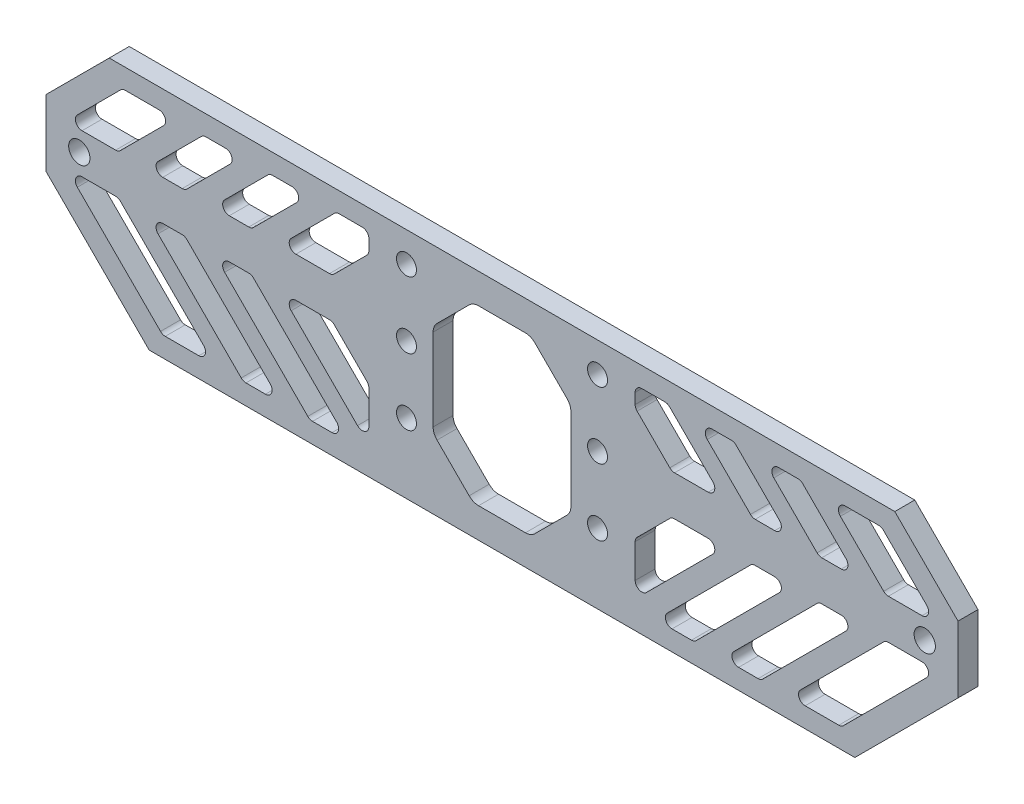
from build123d import *

# Parameters (mm, degrees)
SKETCH_1_W             = 32.7
SKETCH_1_H             = 29
SKETCH_1_R             = 1.5
EXTRUDE_1_DEPTH        = 3
CHAMFER_1_SIZE         = 3
EXTRUDE_2_DEPTH        = 3
CHAMFER_2_SIZE         = 9.5
EXTRUDE_3_DEPTH        = 3
SKETCH_6_R             = 1.6
CUT_EXTRUDE_2_DEPTH    = 4
CUT_EXTRUDE_4_DEPTH    = 10
FILLET_2_R             = 1
FILLET_2_OF_MIRROR_1_R = 1
SKETCH_8_W             = 20.7
SKETCH_8_H             = 26
CUT_EXTRUDE_5_DEPTH    = 10
CHAMFER_3_SIZE         = 6
FILLET_3_R             = 2


with BuildPart() as part:
    # 草图1 → 凸台-拉伸1 (new body)
    with BuildSketch(Plane.XY):
        Rectangle(SKETCH_1_W, SKETCH_1_H)
        with Locations((-14.35, -10)):
            Circle(SKETCH_1_R, mode=Mode.SUBTRACT)
        with Locations((-14.35, 10)):
            Circle(SKETCH_1_R, mode=Mode.SUBTRACT)
        with Locations((14.35, 10)):
            Circle(SKETCH_1_R, mode=Mode.SUBTRACT)
        with Locations((14.35, -10)):
            Circle(SKETCH_1_R, mode=Mode.SUBTRACT)
        with Locations((-14.35, 0)):
            Circle(SKETCH_1_R, mode=Mode.SUBTRACT)
        with Locations((14.35, 0)):
            Circle(SKETCH_1_R, mode=Mode.SUBTRACT)
    extrude(amount=EXTRUDE_1_DEPTH)

    # 倒角1
    chamfer_1_edges = [part.edges().sort_by_distance(p)[0] for p in [
        (16.35, -14.5, 1.5),
        (-16.35, -14.5, 1.5),
        (-16.35, 14.5, 1.5),
        (16.35, 14.5, 1.5),
    ]]
    chamfer(chamfer_1_edges, length=CHAMFER_1_SIZE)

    # 草图3 → 凸台-拉伸2 (add)
    with BuildSketch(Plane.XY.offset(3)):
        Polygon((-13.35, 14.5), (-68.5, 14.5), (-68.5, -14.5), (-13.35, -14.5), (-16.35, -11.5), (-16.35, 11.5), align=None)
        Polygon((68.5, 14.5), (13.35, 14.5), (16.35, 11.5), (16.35, -11.5), (13.35, -14.5), (68.5, -14.5), align=None)
    extrude(amount=-EXTRUDE_2_DEPTH)

    # 倒角2
    chamfer_2_edges = [part.edges().sort_by_distance(p)[0] for p in [
        (-68.5, -14.5, 1.5),
        (-68.5, 14.5, 1.5),
        (68.5, -14.5, 1.5),
        (68.5, 14.5, 1.5),
    ]]
    chamfer(chamfer_2_edges, length=CHAMFER_2_SIZE)

    # 草图4 → 凸台-拉伸3 (add)
    with BuildSketch(Plane(origin=(0, 0, 0), x_dir=(-1, 0, 0), z_dir=(0, 0, -1))):
        Polygon((-59, -14.5), (-53, -20.5), (53, -20.5), (59, -14.5), align=None)
    extrude(amount=-EXTRUDE_3_DEPTH)

    # 草图6 → 切除-拉伸2 (cut, through all)
    with BuildSketch(Plane(origin=(0, 0, 0), x_dir=(-1, 0, 0), z_dir=(0, 0, -1))):
        with Locations((-63.5, 0)):
            Circle(SKETCH_6_R)
    cut_extrude_2 = extrude(amount=-CUT_EXTRUDE_2_DEPTH, mode=Mode.SUBTRACT)

    # 草图7 → 切除-拉伸4 (cut)
    with BuildSketch(Plane(origin=(0, 0, 0), x_dir=(-1, 0, 0), z_dir=(0, 0, -1))):
        Polygon((-57, 11.5), (-65.5, 3), (-57.621320344, 3), (-49.121320344, 11.5), align=None)
        Polygon((-57.621320344, -3), (-65.5, -3), (-51, -17.5), (-43.121320344, -17.5), align=None)
        Polygon((-47.621320344, -3), (-53.378679656, -3), (-38.878679656, -17.5), (-33.121320344, -17.5), align=None)
        Polygon((-44.878679656, 11.5), (-53.378679656, 3), (-47.621320344, 3), (-39.121320344, 11.5), align=None)
        Polygon((-34.878679656, 11.5), (-43.378679656, 3), (-37.621320344, 3), (-29.121320344, 11.5), align=None)
        Polygon((-23.121320344, -17.5), (-37.621320344, -3), (-43.378679656, -3), (-28.878679656, -17.5), align=None)
        Polygon((-20, -8.5), (-25.5, -3), (-33.378679656, -3), (-20, -16.378679656), align=None)
        Polygon((-33.378679656, 3), (-25.5, 3), (-20, 8.5), (-20, 11.5), (-23, 11.5), (-24.878679656, 11.5), align=None)
    cut_extrude_4 = extrude(amount=-CUT_EXTRUDE_4_DEPTH, mode=Mode.SUBTRACT)

    # 圆角2
    fillet_2_edges = [part.edges().sort_by_distance(p)[0] for p in [
        (53.378679656, -3, 1.5),
        (47.621320344, -3, 1.5),
        (33.121320344, -17.5, 1.5),
        (38.878679656, -17.5, 1.5),
        (57.621320344, -3, 1.5),
        (43.121320344, -17.5, 1.5),
        (51, -17.5, 1.5),
        (65.5, -3, 1.5),
        (37.621320344, 3, 1.5),
        (43.378679656, 3, 1.5),
        (34.878679656, 11.5, 1.5),
        (29.121320344, 11.5, 1.5),
        (47.621320344, 3, 1.5),
        (53.378679656, 3, 1.5),
        (44.878679656, 11.5, 1.5),
        (39.121320344, 11.5, 1.5),
        (33.378679656, -3, 1.5),
        (25.5, -3, 1.5),
        (20, -8.5, 1.5),
        (20, -16.378679656, 1.5),
        (43.378679656, -3, 1.5),
        (37.621320344, -3, 1.5),
        (23.121320344, -17.5, 1.5),
        (28.878679656, -17.5, 1.5),
        (33.378679656, 3, 1.5),
        (24.878679656, 11.5, 1.5),
        (20, 11.5, 1.5),
        (20, 8.5, 1.5),
        (25.5, 3, 1.5),
        (57.621320344, 3, 1.5),
        (65.5, 3, 1.5),
        (57, 11.5, 1.5),
        (49.121320344, 11.5, 1.5),
    ]]
    fillet(fillet_2_edges, radius=FILLET_2_R)

    # 镜向1: 切除-拉伸2, 切除-拉伸4 across plane
    add(cut_extrude_2.mirror(Plane(origin=(0, 0, 0), x_dir=(0, 0, 1), z_dir=(1, 0, 0))), mode=Mode.SUBTRACT)
    add(cut_extrude_4.mirror(Plane(origin=(0, 0, 0), x_dir=(0, 0, 1), z_dir=(1, 0, 0))), mode=Mode.SUBTRACT)

    # 圆角2 of 镜向1
    fillet_2_of_mirror_1_edges = [part.edges().sort_by_distance(p)[0] for p in [
        (-53.378679656, -3, 1.5),
        (-47.621320344, -3, 1.5),
        (-33.121320344, -17.5, 1.5),
        (-38.878679656, -17.5, 1.5),
        (-57.621320344, -3, 1.5),
        (-43.121320344, -17.5, 1.5),
        (-51, -17.5, 1.5),
        (-65.5, -3, 1.5),
        (-37.621320344, 3, 1.5),
        (-43.378679656, 3, 1.5),
        (-34.878679656, 11.5, 1.5),
        (-29.121320344, 11.5, 1.5),
        (-47.621320344, 3, 1.5),
        (-53.378679656, 3, 1.5),
        (-44.878679656, 11.5, 1.5),
        (-39.121320344, 11.5, 1.5),
        (-33.378679656, -3, 1.5),
        (-25.5, -3, 1.5),
        (-20, -8.5, 1.5),
        (-20, -16.378679656, 1.5),
        (-43.378679656, -3, 1.5),
        (-37.621320344, -3, 1.5),
        (-23.121320344, -17.5, 1.5),
        (-28.878679656, -17.5, 1.5),
        (-33.378679656, 3, 1.5),
        (-24.878679656, 11.5, 1.5),
        (-20, 11.5, 1.5),
        (-20, 8.5, 1.5),
        (-25.5, 3, 1.5),
        (-57.621320344, 3, 1.5),
        (-65.5, 3, 1.5),
        (-57, 11.5, 1.5),
        (-49.121320344, 11.5, 1.5),
    ]]
    fillet(fillet_2_of_mirror_1_edges, radius=FILLET_2_OF_MIRROR_1_R)

    # 草图8 → 切除-拉伸5 (cut)
    with BuildSketch(Plane.XY.offset(3)):
        with Locations((0, -3)):
            Rectangle(SKETCH_8_W, SKETCH_8_H)
    extrude(amount=-CUT_EXTRUDE_5_DEPTH, mode=Mode.SUBTRACT)

    # 倒角3
    chamfer_3_edges = [part.edges().sort_by_distance(p)[0] for p in [
        (-10.35, -16, 1.5),
        (-10.35, 10, 1.5),
        (10.35, 10, 1.5),
        (10.35, -16, 1.5),
    ]]
    chamfer(chamfer_3_edges, length=CHAMFER_3_SIZE)

    # 圆角3
    fillet_3_edges = [part.edges().sort_by_distance(p)[0] for p in [
        (4.35, -16, 1.5),
        (-4.35, -16, 1.5),
        (-10.35, 4, 1.5),
        (-10.35, -10, 1.5),
        (10.35, 4, 1.5),
        (10.35, -10, 1.5),
        (-4.35, 10, 1.5),
        (4.35, 10, 1.5),
    ]]
    fillet(fillet_3_edges, radius=FILLET_3_R)


solid = part.part
